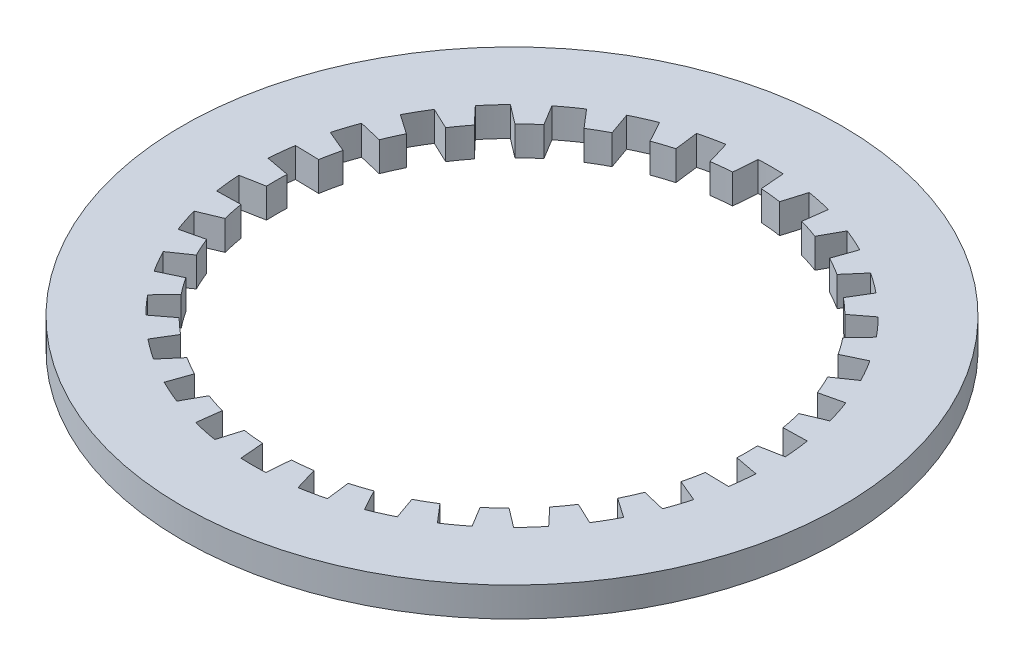
from build123d import *

# Parameters (mm, degrees)
SKETCH1_R           = 17.78
BOSS_EXTRUDE1_DEPTH = 1.5875
CUT_EXTRUDE1_DEPTH  = 2.5875


with BuildPart() as part:
    # Sketch1 → Boss-Extrude1 (new body)
    with BuildSketch(Plane(origin=(0, 0, 0), x_dir=(1, 0, 0), z_dir=(0, 1, 0))):
        Circle(SKETCH1_R)
    extrude(amount=BOSS_EXTRUDE1_DEPTH)

    # Sketch2 → Cut-Extrude1 (cut, through all)
    with BuildSketch(Plane(origin=(0, 1.5875, 0), x_dir=(1, 0, 0), z_dir=(0, 1, 0))):
        with BuildLine():
            Line((-0.670254455, 13.953911959), (-0.775316452, 12.67631194))
            ThreePointArc((-0.775316452, 12.67631194), (-1.327511483, 12.630428071), (-1.877179521, 12.560501465))
            Line((-1.877179521, 12.560501465), (-2.245573641, 13.788339241))
            ThreePointArc((-2.245573641, 13.788339241), (-2.904526321, 13.664721982), (-3.556789216, 13.509631767))
            Line((-3.556789216, 13.509631767), (-3.393927376, 12.238106756))
            ThreePointArc((-3.393927376, 12.238106756), (-3.924515829, 12.078417757), (-4.447633742, 11.895736803))
            Line((-4.447633742, 11.895736803), (-5.063259395, 13.020149934))
            ThreePointArc((-5.063259395, 13.020149934), (-5.682110904, 12.762230043), (-6.287875221, 12.474915839))
            Line((-6.287875221, 12.474915839), (-5.864207388, 11.265037581))
            ThreePointArc((-5.864207388, 11.265037581), (-6.35, 10.998522628), (-6.823705026, 10.711071362))
            Line((-6.823705026, 10.711071362), (-7.659656416, 11.682917597))
            ThreePointArc((-7.659656416, 11.682917597), (-8.211359975, 11.301967411), (-8.744150906, 10.894986229))
            Line((-8.744150906, 10.894986229), (-8.078193398, 9.799632209))
            ThreePointArc((-8.078193398, 9.799632209), (-8.497958701, 9.437939284), (-8.901547657, 9.058280704))
            Line((-8.901547657, 9.058280704), (-9.921289697, 9.835085701))
            ThreePointArc((-9.921289697, 9.835085701), (-10.381733212, 9.347754571), (-10.818265238, 8.83889344))
            Line((-10.818265238, 8.83889344), (-9.939123592, 7.905935885))
            ThreePointArc((-9.939123592, 7.905935885), (-10.274515829, 7.464872704), (-10.59034994, 7.009599713))
            Line((-10.59034994, 7.009599713), (-11.749315011, 7.557413365))
            ThreePointArc((-11.749315011, 7.557413365), (-12.098374891, 6.985), (-12.419569467, 6.396498594))
            Line((-12.419569467, 6.396498594), (-11.365666392, 5.666712226))
            ThreePointArc((-11.365666392, 5.666712226), (-11.602027312, 5.165555367), (-11.816303113, 4.654565579))
            Line((-11.816303113, 4.654565579), (-13.063838879, 4.949445801))
            ThreePointArc((-13.063838879, 4.949445801), (-13.286259533, 4.316967411), (-13.478078914, 3.674546066))
            Line((-13.478078914, 3.674546066), (-12.295475033, 3.179826051))
            ThreePointArc((-12.295475033, 3.179826051), (-12.422474529, 2.640478473), (-12.52582714, 2.096104594))
            Line((-12.52582714, 2.096104594), (-13.807410301, 2.125163705))
            ThreePointArc((-13.807410301, 2.125163705), (-13.893470878, 1.460262632), (-13.947531638, 0.791998242))
            Line((-13.947531638, 0.791998242), (-12.687912414, 0.55396622))
            ThreePointArc((-12.687912414, 0.55396622), (-12.7, 0), (-12.687912414, -0.55396622))
            Line((-12.687912414, -0.55396622), (-13.947531638, -0.791998242))
            ThreePointArc((-13.947531638, -0.791998242), (-13.893470878, -1.460262632), (-13.807410301, -2.125163705))
            Line((-13.807410301, -2.125163705), (-12.52582714, -2.096104594))
            ThreePointArc((-12.52582714, -2.096104594), (-12.422474529, -2.640478473), (-12.295475033, -3.179826051))
            Line((-12.295475033, -3.179826051), (-13.478078914, -3.674546066))
            ThreePointArc((-13.478078914, -3.674546066), (-13.286259533, -4.316967411), (-13.063838879, -4.949445801))
            Line((-13.063838879, -4.949445801), (-11.816303113, -4.654565579))
            ThreePointArc((-11.816303113, -4.654565579), (-11.602027312, -5.165555367), (-11.365666392, -5.666712226))
            Line((-11.365666392, -5.666712226), (-12.419569467, -6.396498594))
            ThreePointArc((-12.419569467, -6.396498594), (-12.098374891, -6.985), (-11.749315011, -7.557413365))
            Line((-11.749315011, -7.557413365), (-10.59034994, -7.009599713))
            ThreePointArc((-10.59034994, -7.009599713), (-10.274515829, -7.464872704), (-9.939123592, -7.905935885))
            Line((-9.939123592, -7.905935885), (-10.818265238, -8.83889344))
            ThreePointArc((-10.818265238, -8.83889344), (-10.381733212, -9.347754571), (-9.921289697, -9.835085701))
            Line((-9.921289697, -9.835085701), (-8.901547657, -9.058280704))
            ThreePointArc((-8.901547657, -9.058280704), (-8.497958701, -9.437939284), (-8.078193398, -9.799632209))
            Line((-8.078193398, -9.799632209), (-8.744150906, -10.894986229))
            ThreePointArc((-8.744150906, -10.894986229), (-8.211359975, -11.301967411), (-7.659656416, -11.682917597))
            Line((-7.659656416, -11.682917597), (-6.823705026, -10.711071362))
            ThreePointArc((-6.823705026, -10.711071362), (-6.35, -10.998522628), (-5.864207388, -11.265037581))
            Line((-5.864207388, -11.265037581), (-6.287875221, -12.474915839))
            ThreePointArc((-6.287875221, -12.474915839), (-5.682110904, -12.762230043), (-5.063259395, -13.020149934))
            Line((-5.063259395, -13.020149934), (-4.447633742, -11.895736803))
            ThreePointArc((-4.447633742, -11.895736803), (-3.924515829, -12.078417757), (-3.393927376, -12.238106756))
            Line((-3.393927376, -12.238106756), (-3.556789216, -13.509631767))
            ThreePointArc((-3.556789216, -13.509631767), (-2.904526321, -13.664721982), (-2.245573641, -13.788339241))
            Line((-2.245573641, -13.788339241), (-1.877179521, -12.560501465))
            ThreePointArc((-1.877179521, -12.560501465), (-1.327511483, -12.630428071), (-0.775316452, -12.67631194))
            Line((-0.775316452, -12.67631194), (-0.670254455, -13.953911959))
            ThreePointArc((-0.670254455, -13.953911959), (0, -13.97), (0.670254455, -13.953911959))
            Line((0.670254455, -13.953911959), (0.775316452, -12.67631194))
            ThreePointArc((0.775316452, -12.67631194), (1.327511483, -12.630428071), (1.877179521, -12.560501465))
            Line((1.877179521, -12.560501465), (2.245573641, -13.788339241))
            ThreePointArc((2.245573641, -13.788339241), (2.904526321, -13.664721982), (3.556789216, -13.509631767))
            Line((3.556789216, -13.509631767), (3.393927376, -12.238106756))
            ThreePointArc((3.393927376, -12.238106756), (3.924515829, -12.078417757), (4.447633742, -11.895736803))
            Line((4.447633742, -11.895736803), (5.063259395, -13.020149934))
            ThreePointArc((5.063259395, -13.020149934), (5.682110904, -12.762230043), (6.287875221, -12.474915839))
            Line((6.287875221, -12.474915839), (5.864207388, -11.265037581))
            ThreePointArc((5.864207388, -11.265037581), (6.35, -10.998522628), (6.823705026, -10.711071362))
            Line((6.823705026, -10.711071362), (7.659656416, -11.682917597))
            ThreePointArc((7.659656416, -11.682917597), (8.211359975, -11.301967411), (8.744150906, -10.894986229))
            Line((8.744150906, -10.894986229), (8.078193398, -9.799632209))
            ThreePointArc((8.078193398, -9.799632209), (8.497958701, -9.437939284), (8.901547657, -9.058280704))
            Line((8.901547657, -9.058280704), (9.921289697, -9.835085701))
            ThreePointArc((9.921289697, -9.835085701), (10.381733212, -9.347754571), (10.818265238, -8.83889344))
            Line((10.818265238, -8.83889344), (9.939123592, -7.905935885))
            ThreePointArc((9.939123592, -7.905935885), (10.274515829, -7.464872704), (10.59034994, -7.009599713))
            Line((10.59034994, -7.009599713), (11.749315011, -7.557413365))
            ThreePointArc((11.749315011, -7.557413365), (12.098374891, -6.985), (12.419569467, -6.396498594))
            Line((12.419569467, -6.396498594), (11.365666392, -5.666712226))
            ThreePointArc((11.365666392, -5.666712226), (11.602027312, -5.165555367), (11.816303113, -4.654565579))
            Line((11.816303113, -4.654565579), (13.063838879, -4.949445801))
            ThreePointArc((13.063838879, -4.949445801), (13.286259533, -4.316967411), (13.478078914, -3.674546066))
            Line((13.478078914, -3.674546066), (12.295475033, -3.179826051))
            ThreePointArc((12.295475033, -3.179826051), (12.422474529, -2.640478473), (12.52582714, -2.096104594))
            Line((12.52582714, -2.096104594), (13.807410301, -2.125163705))
            ThreePointArc((13.807410301, -2.125163705), (13.893470878, -1.460262632), (13.947531638, -0.791998242))
            Line((13.947531638, -0.791998242), (12.687912414, -0.55396622))
            ThreePointArc((12.687912414, -0.55396622), (12.7, 0), (12.687912414, 0.55396622))
            Line((12.687912414, 0.55396622), (13.947531638, 0.791998242))
            ThreePointArc((13.947531638, 0.791998242), (13.893470878, 1.460262632), (13.807410301, 2.125163705))
            Line((13.807410301, 2.125163705), (12.52582714, 2.096104594))
            ThreePointArc((12.52582714, 2.096104594), (12.422474529, 2.640478473), (12.295475033, 3.179826051))
            Line((12.295475033, 3.179826051), (13.478078914, 3.674546066))
            ThreePointArc((13.478078914, 3.674546066), (13.286259533, 4.316967411), (13.063838879, 4.949445801))
            Line((13.063838879, 4.949445801), (11.816303113, 4.654565579))
            ThreePointArc((11.816303113, 4.654565579), (11.602027312, 5.165555367), (11.365666392, 5.666712226))
            Line((11.365666392, 5.666712226), (12.419569467, 6.396498594))
            ThreePointArc((12.419569467, 6.396498594), (12.098374891, 6.985), (11.749315011, 7.557413365))
            Line((11.749315011, 7.557413365), (10.59034994, 7.009599713))
            ThreePointArc((10.59034994, 7.009599713), (10.274515829, 7.464872704), (9.939123592, 7.905935885))
            Line((9.939123592, 7.905935885), (10.818265238, 8.83889344))
            ThreePointArc((10.818265238, 8.83889344), (10.381733212, 9.347754571), (9.921289697, 9.835085701))
            Line((9.921289697, 9.835085701), (8.901547657, 9.058280704))
            ThreePointArc((8.901547657, 9.058280704), (8.497958701, 9.437939284), (8.078193398, 9.799632209))
            Line((8.078193398, 9.799632209), (8.744150906, 10.894986229))
            ThreePointArc((8.744150906, 10.894986229), (8.211359975, 11.301967411), (7.659656416, 11.682917597))
            Line((7.659656416, 11.682917597), (6.823705026, 10.711071362))
            ThreePointArc((6.823705026, 10.711071362), (6.35, 10.998522628), (5.864207388, 11.265037581))
            Line((5.864207388, 11.265037581), (6.287875221, 12.474915839))
            ThreePointArc((6.287875221, 12.474915839), (5.682110904, 12.762230043), (5.063259395, 13.020149934))
            Line((5.063259395, 13.020149934), (4.447633742, 11.895736803))
            ThreePointArc((4.447633742, 11.895736803), (3.924515829, 12.078417757), (3.393927376, 12.238106756))
            Line((3.393927376, 12.238106756), (3.556789216, 13.509631767))
            ThreePointArc((3.556789216, 13.509631767), (2.904526321, 13.664721982), (2.245573641, 13.788339241))
            Line((2.245573641, 13.788339241), (1.877179521, 12.560501465))
            ThreePointArc((1.877179521, 12.560501465), (1.327511483, 12.630428071), (0.775316452, 12.67631194))
            Line((0.775316452, 12.67631194), (0.670254455, 13.953911959))
            ThreePointArc((0.670254455, 13.953911959), (0, 13.97), (-0.670254455, 13.953911959))
        make_face()
    extrude(amount=-CUT_EXTRUDE1_DEPTH, mode=Mode.SUBTRACT)


solid = part.part
